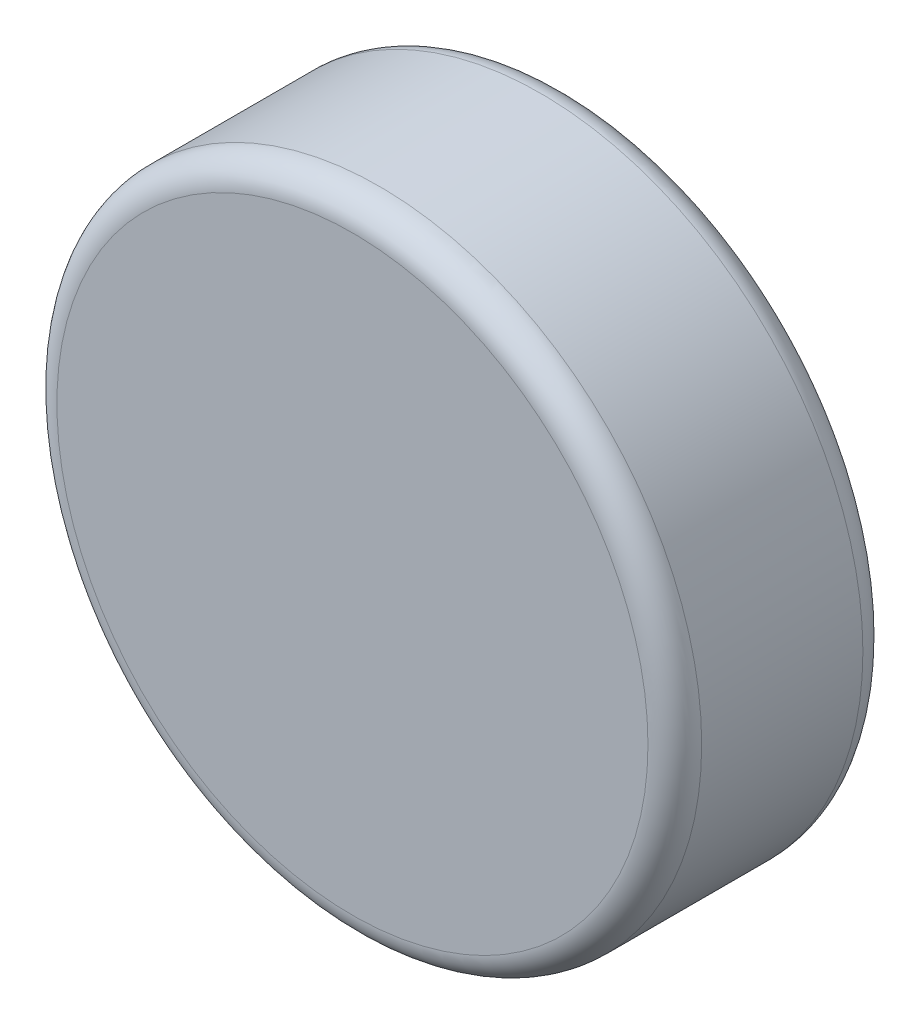
from build123d import *

# Parameters (mm, degrees)
SKETCH1_R           = 3
BOSS_EXTRUDE1_DEPTH = 2
FILLET1_R           = 0.25


with BuildPart() as part:
    # Sketch1 → Boss-Extrude1 (new body)
    with BuildSketch(Plane.XY):
        Circle(SKETCH1_R)
    extrude(amount=BOSS_EXTRUDE1_DEPTH)

    # Fillet1
    fillet1_edges = [part.edges().sort_by_distance(p)[0] for p in [
        (-3, 0, 0),
        (-3, 0, 2),
    ]]
    fillet(fillet1_edges, radius=FILLET1_R)


solid = part.part
